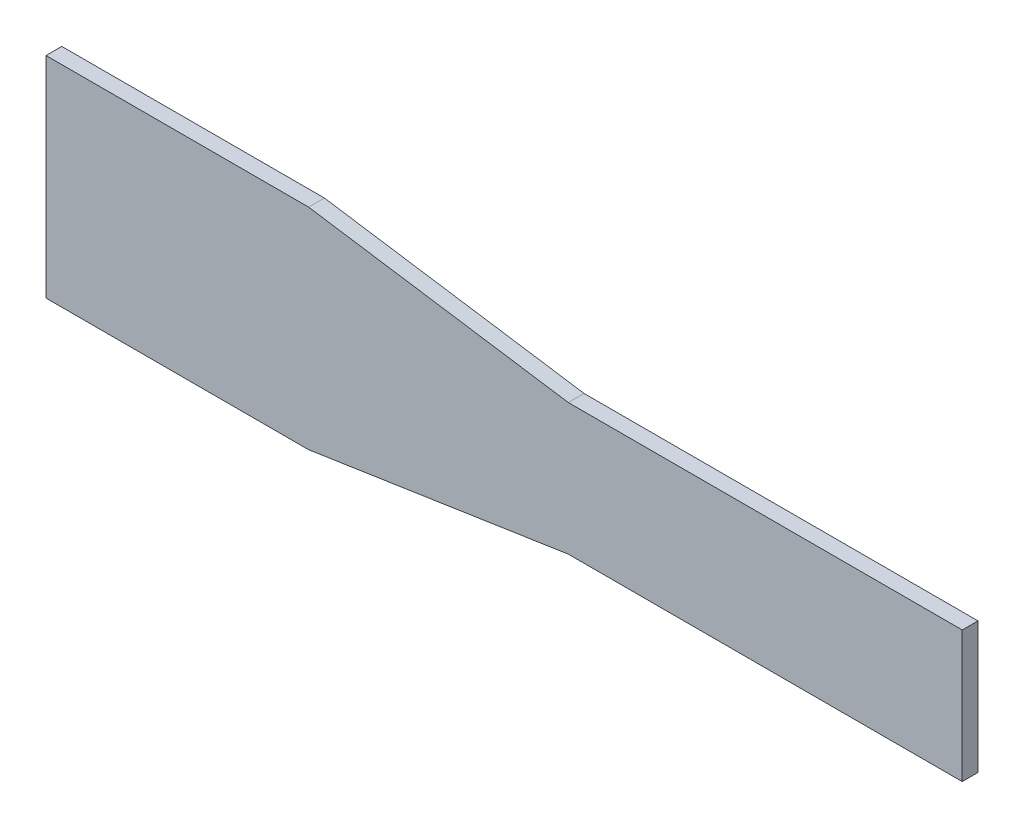
from build123d import *

# Parameters (mm, degrees)
BOSS_EXTRU_1_DEPTH = 3


with BuildPart() as part:
    # Esquisse1 → Boss.-Extru.1 (new body)
    with BuildSketch(Plane.XY):
        Polygon((0, 12.5), (-49.434299833, 20), (-99.434299833, 20), (-99.434299833, -20), (-49.434299833, -20), (0, -12.5), (75, -12.5), (75, 12.5), align=None)
    extrude(amount=BOSS_EXTRU_1_DEPTH)


solid = part.part
